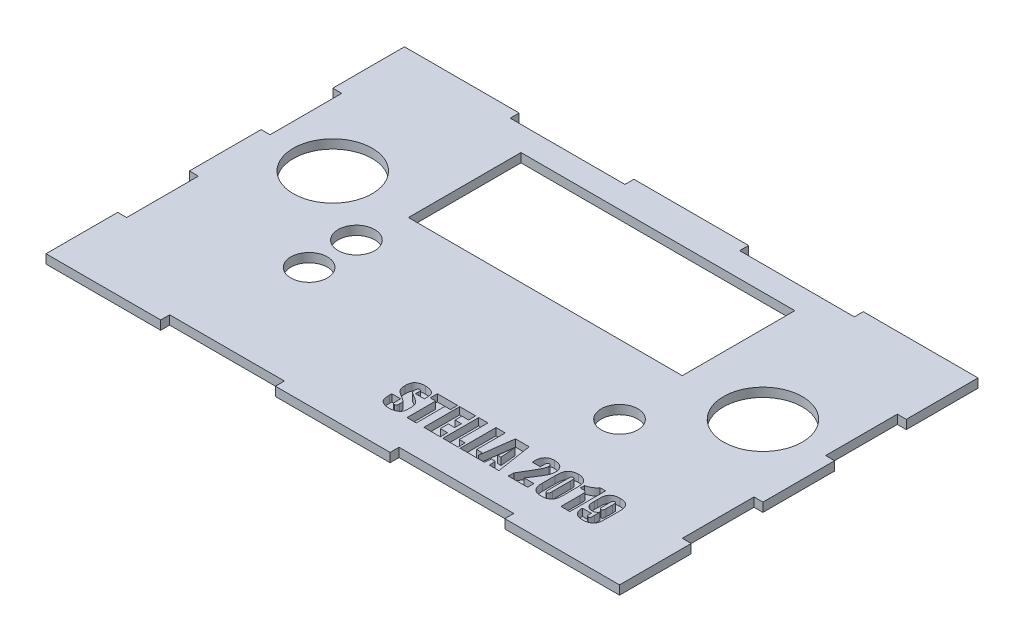
from build123d import *

# Parameters (mm, degrees)
SKETCH1_W           = 203.2
SKETCH1_H           = 127
BOSS_EXTRUDE2_DEPTH = 3.175
SKETCH2_W           = 40.64
SKETCH2_H           = 3.175
CUT_EXTRUDE1_DEPTH  = 3.175
LPATTERN2_COUNT     = 2
LPATTERN2_PITCH     = 81.28
SKETCH3_W           = 3.175
SKETCH3_H           = 25.4
CUT_EXTRUDE2_DEPTH  = 3.175
LPATTERN3_COUNT     = 2
LPATTERN3_PITCH     = 50.8
SKETCH6_W           = 3.175
SKETCH6_H           = 25.4
CUT_EXTRUDE3_DEPTH  = 3.175
LPATTERN4_COUNT     = 2
LPATTERN4_PITCH     = 50.8
SKETCH7_W           = 40.64
SKETCH7_H           = 3.175
CUT_EXTRUDE5_DEPTH  = 3.175
LPATTERN6_COUNT     = 2
LPATTERN6_PITCH     = 81.28
SKETCH9_W           = 97.028
SKETCH9_H           = 39.878
CUT_EXTRUDE6_DEPTH  = 3.175
SKETCH10_R          = 13.97
CUT_EXTRUDE7_DEPTH  = 3.175
SKETCH11_R          = 13.97
SKETCH11_R_2        = 6.477
CUT_EXTRUDE15_DEPTH = 3.175
CUT_EXTRUDE16_DEPTH = 2.54


with BuildPart() as part:
    # Sketch1 → Boss-Extrude2 (new body)
    with BuildSketch(Plane(origin=(0, 0, 0), x_dir=(1, 0, 0), z_dir=(0, 1, 0))):
        Rectangle(SKETCH1_W, SKETCH1_H)
    extrude(amount=BOSS_EXTRUDE2_DEPTH)

    # Sketch2 → Cut-Extrude1 (cut)
    with BuildSketch(Plane(origin=(0, 3.175, 0), x_dir=(1, 0, 0), z_dir=(0, 1, 0))):
        with Locations((-40.64, -61.9125)):
            Rectangle(SKETCH2_W, SKETCH2_H)
    cut_extrude1 = extrude(amount=-CUT_EXTRUDE1_DEPTH, mode=Mode.SUBTRACT)

    # LPattern2: Cut-Extrude1 ×2
    with Locations(*[(i * LPATTERN2_PITCH, 0, 0) for i in range(1, LPATTERN2_COUNT)]):
        add(cut_extrude1, mode=Mode.SUBTRACT)

    # Sketch3 → Cut-Extrude2 (cut)
    with BuildSketch(Plane(origin=(0, 3.175, 0), x_dir=(1, 0, 0), z_dir=(0, 1, 0))):
        with Locations((-100.0125, -25.4)):
            Rectangle(SKETCH3_W, SKETCH3_H)
    cut_extrude2 = extrude(amount=-CUT_EXTRUDE2_DEPTH, mode=Mode.SUBTRACT)

    # LPattern3: Cut-Extrude2 ×2
    with Locations(*[(0, 0, -i * LPATTERN3_PITCH) for i in range(1, LPATTERN3_COUNT)]):
        add(cut_extrude2, mode=Mode.SUBTRACT)

    # Sketch6 → Cut-Extrude3 (cut)
    with BuildSketch(Plane(origin=(0, 3.175, 0), x_dir=(1, 0, 0), z_dir=(0, 1, 0))):
        with Locations((100.0125, -25.4)):
            Rectangle(SKETCH6_W, SKETCH6_H)
    cut_extrude3 = extrude(amount=-CUT_EXTRUDE3_DEPTH, mode=Mode.SUBTRACT)

    # LPattern4: Cut-Extrude3 ×2
    with Locations(*[(0, 0, -i * LPATTERN4_PITCH) for i in range(1, LPATTERN4_COUNT)]):
        add(cut_extrude3, mode=Mode.SUBTRACT)

    # Sketch7 → Cut-Extrude5 (cut)
    with BuildSketch(Plane(origin=(0, 3.175, 0), x_dir=(1, 0, 0), z_dir=(0, 1, 0))):
        with Locations((-40.64, 61.9125)):
            Rectangle(SKETCH7_W, SKETCH7_H)
    cut_extrude5 = extrude(amount=-CUT_EXTRUDE5_DEPTH, mode=Mode.SUBTRACT)

    # LPattern6: Cut-Extrude5 ×2
    with Locations(*[(i * LPATTERN6_PITCH, 0, 0) for i in range(1, LPATTERN6_COUNT)]):
        add(cut_extrude5, mode=Mode.SUBTRACT)

    # Sketch9 → Cut-Extrude6 (cut)
    with BuildSketch(Plane(origin=(0, 3.175, 0), x_dir=(1, 0, 0), z_dir=(0, 1, 0))):
        with Locations((0, 31.75)):
            Rectangle(SKETCH9_W, SKETCH9_H)
    extrude(amount=-CUT_EXTRUDE6_DEPTH, mode=Mode.SUBTRACT)

    # Sketch10 → Cut-Extrude7 (cut)
    with BuildSketch(Plane(origin=(0, 3.175, 0), x_dir=(1, 0, 0), z_dir=(0, 1, 0))):
        with Locations((-76.2, 12.7)):
            Circle(SKETCH10_R)
    extrude(amount=-CUT_EXTRUDE7_DEPTH, mode=Mode.SUBTRACT)

    # Sketch11 → Cut-Extrude15 (cut)
    with BuildSketch(Plane(origin=(0, 3.175, 0), x_dir=(1, 0, 0), z_dir=(0, 1, 0))):
        with Locations((76.2, 12.7)):
            Circle(SKETCH11_R)
        with Locations((-50.8, -4.318)):
            Circle(SKETCH11_R_2)
        with Locations((-50.8, -21.082)):
            Circle(SKETCH11_R_2)
        with Locations((50.8, -12.7)):
            Circle(SKETCH11_R_2)
    extrude(amount=-CUT_EXTRUDE15_DEPTH, mode=Mode.SUBTRACT)

    # Sketch12 → Cut-Extrude16 (cut)
    with BuildSketch(Plane(origin=(0, 3.175, 0), x_dir=(1, 0, 0), z_dir=(0, 1, 0))):
        with BuildLine():
            Line((9.930258202, -41.00708394), (6.792611143, -41.00708394))
            Line((6.792611143, -41.00708394), (6.792611143, -40.003223645))
            add(Edge.make_bspline(
                [(6.792611143, -40.003223645), (6.791812116, -39.896558981), (6.790374848, -39.704693759), (6.76848043, -39.448334636), (6.733262434, -39.254011954), (6.677701373, -39.113864424), (6.597300117, -39.01992962), (6.498249038, -38.959276857), (6.379142296, -38.919770101), (6.292593657, -38.916869766), (6.246324379, -38.915319234)],
                knots=[0, 0, 0, 0, 0.000319911, 0.000575447, 0.000770951, 0.000911044, 0.001021954, 0.001135295, 0.001255632, 0.001393865, 0.001393865, 0.001393865, 0.001393865], degree=3))
            add(Edge.make_bspline(
                [(6.246324379, -38.915319234), (6.196136753, -38.918351267), (6.099594777, -38.924183749), (5.963481861, -38.972332752), (5.848467833, -39.05500618), (5.752748404, -39.168462924), (5.679995413, -39.314803852), (5.634707481, -39.493741734), (5.59998927, -39.702299025), (5.598246811, -39.852851348), (5.597317026, -39.933186881)],
                knots=[0, 0, 0, 0, 0.000150303, 0.000289126, 0.000426449, 0.000570531, 0.000730273, 0.000912099, 0.00112243, 0.001363071, 0.001363071, 0.001363071, 0.001363071], degree=3))
            add(Edge.make_bspline(
                [(5.597317026, -39.933186881), (5.598489748, -40.036820334), (5.600682477, -40.230591629), (5.632302643, -40.500441071), (5.675630111, -40.73214216), (5.730716931, -40.866075093), (5.756067026, -40.92770894)],
                knots=[0, 0, 0, 0, 0.000310637, 0.000580821, 0.000814801, 0.001014266, 0.001014266, 0.001014266, 0.001014266], degree=3))
            add(Edge.make_bspline(
                [(5.756067026, -40.92770894), (5.771709844, -40.956173484), (5.805294139, -41.017285341), (5.875214301, -41.106022637), (5.96406191, -41.200173191), (6.076752729, -41.293222984), (6.206720453, -41.393348976), (6.358202789, -41.495088099), (6.531327924, -41.599287217), (6.653928921, -41.668828569), (6.717905261, -41.705117028)],
                knots=[0, 0, 0, 0, 9.7298e-05, 0.000208894, 0.000337697, 0.000485071, 0.000646628, 0.000829873, 0.001032065, 0.001252715, 0.001252715, 0.001252715, 0.001252715], degree=3))
            add(Edge.make_bspline(
                [(6.717905261, -41.705117028), (6.902854819, -41.808487249), (7.257197705, -42.006533153), (7.757655385, -42.305166833), (8.203623955, -42.590925405), (8.594647297, -42.865176377), (8.934590897, -43.121551001), (9.217696681, -43.368536753), (9.454480219, -43.595727727), (9.577108637, -43.757262704), (9.633769232, -43.831900116)],
                knots=[0, 0, 0, 0, 0.000635605, 0.001217748, 0.00174811, 0.002224142, 0.002650453, 0.003024464, 0.003351319, 0.003632059, 0.003632059, 0.003632059, 0.003632059], degree=3))
            add(Edge.make_bspline(
                [(9.633769232, -43.831900116), (9.682316521, -43.90711219), (9.78303355, -44.063148434), (9.902342903, -44.326786714), (10.002340127, -44.622016067), (10.085530663, -44.948304687), (10.150591979, -45.307933791), (10.195879875, -45.699371677), (10.224263415, -46.123239014), (10.227437281, -46.4162089), (10.229081732, -46.568003057)],
                knots=[0, 0, 0, 0, 0.000268261, 0.000556539, 0.000865142, 0.001202613, 0.001565733, 0.001960708, 0.002384191, 0.002839526, 0.002839526, 0.002839526, 0.002839526], degree=3))
            add(Edge.make_bspline(
                [(10.229081732, -46.568003057), (10.228460745, -46.678529142), (10.227257382, -46.892709138), (10.210247897, -47.202613351), (10.18497434, -47.489977746), (10.151304335, -47.754446323), (10.10405423, -47.995872283), (10.04893836, -48.215222712), (9.984053207, -48.413265823), (9.906545645, -48.591122587), (9.813269663, -48.753873257), (9.701953852, -48.906359376), (9.573566845, -49.053751915), (9.425454528, -49.193896726), (9.258724221, -49.327927409), (9.071800281, -49.452567732), (8.866729648, -49.572484862), (8.5672061, -49.725948343), (8.158411383, -49.884986144), (7.632443943, -50.023841232), (7.06830021, -50.10536844), (6.679262403, -50.115834853), (6.479780261, -50.121201587)],
                knots=[0, 0, 0, 0, 0.00033154, 0.000642466, 0.000930763, 0.001196882, 0.001441833, 0.001668321, 0.001875032, 0.002066323, 0.00224933, 0.00243659, 0.002631829, 0.002834936, 0.003047496, 0.003272826, 0.003508258, 0.003759882, 0.004281843, 0.004820362, 0.005388893, 0.005987196, 0.005987196, 0.005987196, 0.005987196], degree=3))
            add(Edge.make_bspline(
                [(6.479780261, -50.121201587), (6.368434133, -50.120375011), (6.150093984, -50.118754167), (5.829260674, -50.09071429), (5.521129398, -50.052815232), (5.225021607, -49.995866366), (4.940786711, -49.924765027), (4.669365705, -49.834557911), (4.40882034, -49.733773576), (4.165204222, -49.611330395), (3.936649657, -49.478937699), (3.726939039, -49.337733141), (3.538218714, -49.186791726), (3.369388711, -49.028389792), (3.22106123, -48.859825291), (3.095556825, -48.681107752), (2.985589074, -48.496899088), (2.901492723, -48.298030088), (2.832167132, -48.08586399), (2.770069021, -47.855526761), (2.723800316, -47.603722659), (2.680432958, -47.331499515), (2.648875285, -47.038503001), (2.625650258, -46.724728475), (2.611570612, -46.390705437), (2.609927847, -46.161025431), (2.609081732, -46.042727322)],
                knots=[0, 0, 0, 0, 0.000333915, 0.000654779, 0.000965486, 0.001264929, 0.001558796, 0.001843765, 0.002122518, 0.00239606, 0.002660732, 0.002914555, 0.003153731, 0.003384935, 0.003608285, 0.003825938, 0.004039355, 0.004250565, 0.004472041, 0.004708743, 0.004965597, 0.005239647, 0.005535611, 0.005849312, 0.006183448, 0.006538332, 0.006538332, 0.006538332, 0.006538332], degree=3))
            Line((2.609081732, -46.042727322), (2.609081732, -45.190613351))
            Line((2.609081732, -45.190613351), (5.74672879, -45.190613351))
            Line((5.74672879, -45.190613351), (5.74672879, -46.836477322))
            add(Edge.make_bspline(
                [(5.74672879, -46.836477322), (5.747014256, -46.897192584), (5.747556122, -47.012441437), (5.755925607, -47.17656627), (5.762753416, -47.32410626), (5.781086104, -47.45452808), (5.796811272, -47.569236818), (5.824026261, -47.665341613), (5.850571078, -47.745967972), (5.893511749, -47.830272973), (5.967185741, -47.913383126), (6.082459454, -47.983616305), (6.225268657, -48.022322806), (6.328574136, -48.026950939), (6.384063349, -48.029436881)],
                knots=[0, 0, 0, 0, 0.000182111, 0.00034568, 0.000493053, 0.000624806, 0.000740714, 0.000839816, 0.000923989, 0.000994992, 0.00112237, 0.0012513, 0.001394643, 0.001560988, 0.001560988, 0.001560988, 0.001560988], degree=3))
            add(Edge.make_bspline(
                [(6.384063349, -48.029436881), (6.440608276, -48.026974272), (6.548576734, -48.022272099), (6.697343703, -47.967975646), (6.825075766, -47.88451677), (6.923952004, -47.761774748), (7.002162807, -47.608659715), (7.052371096, -47.422673369), (7.085711992, -47.206532891), (7.089439057, -47.052188952), (7.091434673, -46.969547175)],
                knots=[0, 0, 0, 0, 0.000168881, 0.000322466, 0.0004688, 0.000621245, 0.000789349, 0.000981437, 0.001196381, 0.00144412, 0.00144412, 0.00144412, 0.00144412], degree=3))
            add(Edge.make_bspline(
                [(7.091434673, -46.969547175), (7.090641082, -46.877697109), (7.089120138, -46.70166334), (7.074914372, -46.450116264), (7.053286803, -46.22218506), (7.017528317, -46.020664823), (6.977611145, -45.842341704), (6.923068758, -45.691502868), (6.864768269, -45.560889893), (6.81103241, -45.490199828), (6.785607467, -45.456753057)],
                knots=[0, 0, 0, 0, 0.000275518, 0.000528039, 0.000755691, 0.000961794, 0.001141858, 0.001302824, 0.001442742, 0.001568397, 0.001568397, 0.001568397, 0.001568397], degree=3))
            add(Edge.make_bspline(
                [(6.785607467, -45.456753057), (6.754988982, -45.424321714), (6.686103225, -45.351357369), (6.559067272, -45.243610082), (6.400983405, -45.122697766), (6.215415254, -44.984696089), (5.996655154, -44.835567573), (5.747802421, -44.672556076), (5.46582187, -44.497506911), (5.267452007, -44.376487745), (5.163089085, -44.312819234)],
                knots=[0, 0, 0, 0, 0.000133724, 0.000300853, 0.00049885, 0.000730913, 0.00099447, 0.001292974, 0.001623337, 0.001990093, 0.001990093, 0.001990093, 0.001990093], degree=3))
            add(Edge.make_bspline(
                [(5.163089085, -44.312819234), (5.058682428, -44.249218905), (4.857834224, -44.12687027), (4.572038773, -43.948161624), (4.313628539, -43.781645021), (4.08444486, -43.628509712), (3.881396979, -43.49018674), (3.707196836, -43.364640223), (3.558964609, -43.253119596), (3.398250217, -43.118837999), (3.224560465, -42.939868848), (3.039495169, -42.697927099), (2.874190832, -42.420070202), (2.72545922, -42.107202968), (2.602085284, -41.752887528), (2.522635533, -41.351487138), (2.466293031, -40.907512197), (2.461941863, -40.595628037), (2.459669967, -40.432782469)],
                knots=[0, 0, 0, 0, 0.000366756, 0.000705533, 0.001011182, 0.001288955, 0.001532433, 0.001748187, 0.001933089, 0.002088824, 0.002376079, 0.002679122, 0.003000622, 0.003344191, 0.003717027, 0.004122703, 0.004569508, 0.005057704, 0.005057704, 0.005057704, 0.005057704], degree=3))
            add(Edge.make_bspline(
                [(2.459669967, -40.432782469), (2.461388237, -40.313710089), (2.464702872, -40.084013158), (2.47944386, -39.752043768), (2.510340609, -39.445196786), (2.551251314, -39.162911515), (2.605115813, -38.904891477), (2.668586313, -38.670633422), (2.748566023, -38.462685818), (2.838188287, -38.276171048), (2.942826978, -38.107515416), (3.062857305, -37.952219547), (3.193707431, -37.802083672), (3.343895811, -37.666487567), (3.506399567, -37.536433563), (3.682938857, -37.415213209), (3.875726129, -37.30588588), (4.15435752, -37.169441679), (4.536256166, -37.029181668), (5.033274538, -36.907830116), (5.574172539, -36.835388615), (5.949607806, -36.827586209), (6.14360379, -36.823554528)],
                knots=[0, 0, 0, 0, 0.000357256, 0.000689166, 0.000996495, 0.001282086, 0.001544441, 0.001786875, 0.002009296, 0.002211852, 0.002406854, 0.002603429, 0.002800212, 0.003003426, 0.003209423, 0.003424405, 0.003645055, 0.003873711, 0.004354613, 0.004861943, 0.005406061, 0.005987835, 0.005987835, 0.005987835, 0.005987835], degree=3))
            add(Edge.make_bspline(
                [(6.14360379, -36.823554528), (6.251781958, -36.825177227), (6.464408357, -36.828366677), (6.777135137, -36.845201488), (7.076451787, -36.882979815), (7.364836287, -36.924260515), (7.64006868, -36.986915685), (7.904166278, -37.057708231), (8.155220591, -37.144620494), (8.392436846, -37.245060834), (8.614164576, -37.354000943), (8.819843294, -37.46686081), (9.001188517, -37.59334443), (9.169518321, -37.71843422), (9.310835443, -37.859519463), (9.439932194, -38.000591012), (9.544173337, -38.152990316), (9.631877199, -38.314700072), (9.701488905, -38.494995259), (9.765105304, -38.697333508), (9.814490828, -38.929030738), (9.859808616, -39.187294871), (9.890751761, -39.475121017), (9.913902355, -39.790458766), (9.927823185, -40.133835428), (9.929425782, -40.372071182), (9.930258202, -40.495815557)],
                knots=[0, 0, 0, 0, 0.000324579, 0.000637967, 0.000938836, 0.001229392, 0.001511478, 0.00178503, 0.002049341, 0.002307761, 0.002557297, 0.002790402, 0.003010557, 0.003220226, 0.003418347, 0.003608539, 0.003793102, 0.003970667, 0.004159246, 0.004371909, 0.00460639, 0.004869295, 0.0051583, 0.005474329, 0.005817794, 0.006189019, 0.006189019, 0.006189019, 0.006189019], degree=3))
            Line((9.930258202, -40.495815557), (9.930258202, -41.00708394))
        make_face()
        Polygon((17.849081732, -37.122378057), (17.849081732, -39.662378057), (15.90672879, -39.662378057), (15.90672879, -49.822378057), (12.619669967, -49.822378057), (12.619669967, -39.662378057), (10.677317026, -39.662378057), (10.677317026, -37.122378057), align=None)
        Polygon((18.596140555, -37.122378057), (24.273787614, -37.122378057), (24.273787614, -39.662378057), (21.883199379, -39.662378057), (21.883199379, -42.052966293), (24.124375849, -42.052966293), (24.124375849, -44.443554528), (21.883199379, -44.443554528), (21.883199379, -47.282378057), (24.423199379, -47.282378057), (24.423199379, -49.822378057), (18.596140555, -49.822378057), align=None)
        Polygon((28.60672879, -37.122378057), (28.60672879, -47.282378057), (30.698493496, -47.282378057), (30.698493496, -49.822378057), (25.319669967, -49.822378057), (25.319669967, -37.122378057), align=None)
        Polygon((34.732611143, -37.122378057), (34.732611143, -47.282378057), (36.824375849, -47.282378057), (36.824375849, -49.822378057), (31.44555232, -49.822378057), (31.44555232, -37.122378057), align=None)
        Polygon((43.21172879, -37.122378057), (45.191434673, -49.822378057), (41.792317026, -49.822378057), (41.600883202, -47.581201587), (40.267850114, -47.581201587), (40.074081732, -49.822378057), (36.674964085, -49.822378057), (38.355846437, -37.122378057), align=None)
        with BuildLine():
            add(Edge.make_bspline(
                [(41.44680232, -45.340025116), (41.428789132, -45.148601983), (41.391739699, -44.754883858), (41.336872252, -44.147717685), (41.273892266, -43.507626668), (41.216372579, -42.833206147), (41.145406865, -42.12557754), (41.080179626, -41.383591005), (41.006473047, -40.608713296), (40.957957208, -40.08105565), (40.933199379, -39.811789822)],
                knots=[0, 0, 0, 0, 0.000576806, 0.001186372, 0.001828914, 0.002506327, 0.003216931, 0.003962401, 0.004740846, 0.005552051, 0.005552051, 0.005552051, 0.005552051], degree=3))
            add(Edge.make_bspline(
                [(40.933199379, -39.811789822), (40.89770827, -40.113762781), (40.829092604, -40.697573119), (40.724781114, -41.542305235), (40.632424803, -42.326155628), (40.546023422, -43.04830956), (40.465624833, -43.707997252), (40.397351738, -44.306818175), (40.330268713, -44.843375637), (40.290981368, -45.18124948), (40.272519232, -45.340025116)],
                knots=[0, 0, 0, 0, 0.000912152, 0.001763483, 0.002553433, 0.003279965, 0.003945396, 0.004547133, 0.005088046, 0.00556758, 0.00556758, 0.00556758, 0.00556758], degree=3))
            Line((40.272519232, -45.340025116), (41.44680232, -45.340025116))
        make_face(mode=Mode.SUBTRACT)
        with BuildLine():
            Line((55.351434673, -47.581201587), (55.351434673, -49.822378057))
            Line((55.351434673, -49.822378057), (48.478493496, -49.822378057))
            Line((48.478493496, -49.822378057), (48.515846437, -47.880025116))
            add(Edge.make_bspline(
                [(48.515846437, -47.880025116), (48.639716134, -47.675445523), (48.881095488, -47.276790394), (49.231877588, -46.692259092), (49.561782283, -46.137234046), (49.876587095, -45.61437303), (50.167261081, -45.119079766), (50.440643792, -44.654644924), (50.695186511, -44.220458747), (50.930640539, -43.816387001), (51.14918312, -43.443343168), (51.34349137, -43.097907242), (51.52233798, -42.784326417), (51.681008908, -42.500651236), (51.818395573, -42.245558477), (51.938559895, -42.021224988), (52.03782725, -41.826083805), (52.146172913, -41.61095618), (52.25941177, -41.368908722), (52.375846546, -41.094631999), (52.474400859, -40.8360173), (52.557688066, -40.595417093), (52.616799911, -40.369152319), (52.666802039, -40.161411125), (52.692336199, -39.968068929), (52.697115754, -39.844528082), (52.699375849, -39.786109675)],
                knots=[0, 0, 0, 0, 0.000717473, 0.001398108, 0.002045114, 0.002654483, 0.003229036, 0.00376796, 0.004271257, 0.004738926, 0.005170971, 0.005568258, 0.005927901, 0.006253972, 0.006543325, 0.006797106, 0.007017409, 0.007200118, 0.007519705, 0.007818893, 0.008093777, 0.008349951, 0.008582143, 0.008795101, 0.008990563, 0.009165904, 0.009165904, 0.009165904, 0.009165904], degree=3))
            add(Edge.make_bspline(
                [(52.699375849, -39.786109675), (52.696959797, -39.705873496), (52.692436415, -39.555653735), (52.664264001, -39.345623249), (52.611407306, -39.167730709), (52.536218349, -39.021138544), (52.439146528, -38.903950311), (52.315042, -38.821854065), (52.168020852, -38.774710615), (52.063169887, -38.768929987), (52.008346437, -38.765907469)],
                knots=[0, 0, 0, 0, 0.000240743, 0.000450723, 0.000633863, 0.000794677, 0.00094205, 0.001085146, 0.001235013, 0.001399247, 0.001399247, 0.001399247, 0.001399247], degree=3))
            add(Edge.make_bspline(
                [(52.008346437, -38.765907469), (51.953430523, -38.768543701), (51.847894567, -38.773609941), (51.700367149, -38.826698486), (51.576685639, -38.91655759), (51.496255005, -39.020208121), (51.444751101, -39.121704463), (51.409093968, -39.216150976), (51.383932109, -39.328142357), (51.356282639, -39.455226975), (51.338526894, -39.600513531), (51.328790014, -39.762692534), (51.317527069, -39.941605892), (51.317389306, -40.066234925), (51.317317026, -40.131624381)],
                knots=[0, 0, 0, 0, 0.000164234, 0.000315621, 0.000462717, 0.00061731, 0.000703972, 0.000803704, 0.000919212, 0.001047867, 0.001193809, 0.001357645, 0.001535317, 0.001731434, 0.001731434, 0.001731434, 0.001731434], degree=3))
            Line((51.317317026, -40.131624381), (51.317317026, -41.305907469))
            Line((51.317317026, -41.305907469), (48.478493496, -41.305907469))
            Line((48.478493496, -41.305907469), (48.478493496, -40.850668498))
            add(Edge.make_bspline(
                [(48.478493496, -40.850668498), (48.479625122, -40.685666013), (48.481766646, -40.373410311), (48.503050052, -39.932694056), (48.53438954, -39.546998206), (48.578728397, -39.206424486), (48.654902669, -38.893770997), (48.771816348, -38.593920094), (48.924313772, -38.2948459), (49.116909954, -38.004504839), (49.341740171, -37.729003128), (49.606873734, -37.488821395), (49.903368472, -37.285123247), (50.231222367, -37.114517353), (50.593834978, -36.985513428), (50.987822486, -36.88921163), (51.416112904, -36.833470985), (51.712471315, -36.826937727), (51.865938349, -36.823554528)],
                knots=[0, 0, 0, 0, 0.000494976, 0.000936708, 0.001323294, 0.001655762, 0.001966047, 0.002286018, 0.002619084, 0.002971324, 0.003329418, 0.003683071, 0.004040533, 0.004405986, 0.004788541, 0.005192257, 0.005620825, 0.006081113, 0.006081113, 0.006081113, 0.006081113], degree=3))
            add(Edge.make_bspline(
                [(51.865938349, -36.823554528), (52.017034003, -36.825830653), (52.310581404, -36.83025269), (52.73654567, -36.876215243), (53.134583921, -36.946330948), (53.504392209, -37.04968905), (53.845650329, -37.182097238), (54.158508968, -37.343363416), (54.442139407, -37.534561644), (54.696319745, -37.753751753), (54.919266723, -37.997022912), (55.115117011, -38.255598139), (55.281120702, -38.529284598), (55.418564825, -38.818061311), (55.520532016, -39.124365457), (55.594470942, -39.444848991), (55.643944367, -39.780691528), (55.648126477, -40.010047064), (55.650258202, -40.126955263)],
                knots=[0, 0, 0, 0, 0.000453121, 0.00088032, 0.001283739, 0.001664387, 0.002030288, 0.002380082, 0.002718078, 0.0030541, 0.00338452, 0.003706224, 0.004025726, 0.0043432, 0.004663605, 0.004992049, 0.00532914, 0.005679604, 0.005679604, 0.005679604, 0.005679604], degree=3))
            add(Edge.make_bspline(
                [(55.650258202, -40.126955263), (55.648262649, -40.218060806), (55.644229968, -40.402169956), (55.61734748, -40.680407236), (55.575517772, -40.962530442), (55.516739147, -41.249445853), (55.440011439, -41.539279658), (55.344912302, -41.833219609), (55.236377999, -42.131566042), (55.127938795, -42.38495471), (55.026527382, -42.599409947), (54.934743012, -42.783552251), (54.824796509, -42.9877505), (54.698692535, -43.21421115), (54.556054848, -43.461571513), (54.397297275, -43.730063875), (54.221285402, -44.019779769), (54.031338652, -44.331983288), (53.821736371, -44.663917485), (53.598875107, -45.019292709), (53.355731201, -45.393167157), (53.09849908, -45.790000853), (52.82286432, -46.205987113), (52.533321213, -46.646652378), (52.226076366, -47.107444593), (52.013974948, -47.421017283), (51.905625849, -47.581201587)],
                knots=[0, 0, 0, 0, 0.000273303, 0.0005523, 0.00083789, 0.001128625, 0.001430442, 0.001736839, 0.002055171, 0.002382559, 0.002563227, 0.002766816, 0.002999723, 0.003258901, 0.003544415, 0.003856312, 0.00419463, 0.004561386, 0.004952625, 0.005372326, 0.005819789, 0.006290543, 0.006791059, 0.007316828, 0.007872374, 0.008452534, 0.008452534, 0.008452534, 0.008452534], degree=3))
            Line((51.905625849, -47.581201587), (55.351434673, -47.581201587))
        make_face()
        with BuildLine():
            Line((64.16672879, -41.40395894), (64.16672879, -45.676201587))
            add(Edge.make_bspline(
                [(64.16672879, -45.676201587), (64.166345825, -45.792935543), (64.165605352, -46.018643781), (64.158111836, -46.345496282), (64.148273316, -46.647647622), (64.127368214, -46.925260438), (64.109376782, -47.177907944), (64.079249573, -47.405603113), (64.051046005, -47.609426591), (64.001566636, -47.848158505), (63.915903161, -48.126114044), (63.774708872, -48.445122508), (63.58830778, -48.751575318), (63.363466331, -49.042566421), (63.108008381, -49.310822341), (62.819149905, -49.538626525), (62.507589923, -49.730273792), (62.167942012, -49.877018954), (61.806666609, -49.984669149), (61.425803081, -50.065221233), (61.024000362, -50.111513264), (60.749050863, -50.117929905), (60.608861143, -50.121201587)],
                knots=[0, 0, 0, 0, 0.000350192, 0.000677105, 0.000980822, 0.001256932, 0.001512265, 0.001740444, 0.001945805, 0.002129406, 0.002471313, 0.002816204, 0.003173338, 0.003544563, 0.003917698, 0.004281567, 0.004645114, 0.005012056, 0.005387949, 0.005774387, 0.006178637, 0.006599175, 0.006599175, 0.006599175, 0.006599175], degree=3))
            add(Edge.make_bspline(
                [(60.608861143, -50.121201587), (60.427444232, -50.11823837), (60.079453752, -50.112554384), (59.581011267, -50.064987925), (59.130626327, -49.980592229), (58.724372703, -49.868954935), (58.362124087, -49.71634527), (58.041452222, -49.524509456), (57.75472226, -49.300718688), (57.513641276, -49.036104229), (57.307919459, -48.752923197), (57.134302661, -48.457883409), (56.988231555, -48.158388432), (56.894858, -47.897132339), (56.834303202, -47.674533162), (56.799248174, -47.483737606), (56.765456308, -47.270636916), (56.741552912, -47.035172671), (56.719394485, -46.776870706), (56.707087811, -46.495716829), (56.696599353, -46.191439497), (56.696297196, -45.981261976), (56.696140555, -45.872304528)],
                knots=[0, 0, 0, 0, 0.000544198, 0.00104387, 0.001499916, 0.001917437, 0.002305521, 0.002675068, 0.003035657, 0.003392471, 0.00374502, 0.004084143, 0.004418278, 0.004743193, 0.004914779, 0.005109823, 0.005324767, 0.005561952, 0.005819612, 0.00610244, 0.006406077, 0.006732923, 0.006732923, 0.006732923, 0.006732923], degree=3))
            Line((56.696140555, -45.872304528), (56.696140555, -41.40395894))
            add(Edge.make_bspline(
                [(56.696140555, -41.40395894), (56.696964686, -41.261537601), (56.698559335, -40.985960082), (56.712823813, -40.585841868), (56.735294819, -40.213638231), (56.768309017, -39.868763357), (56.808141882, -39.552056683), (56.86349667, -39.263600354), (56.922372954, -39.001936923), (56.993019048, -38.764446276), (57.076915962, -38.54516674), (57.183606224, -38.342499534), (57.305221479, -38.148283098), (57.4483202, -37.967428667), (57.607456905, -37.795414239), (57.786700886, -37.636572034), (57.982831797, -37.486756998), (58.197544476, -37.349320248), (58.427446967, -37.226962451), (58.669634368, -37.11816799), (58.924346472, -37.027770488), (59.191110986, -36.952937115), (59.469597932, -36.894958818), (59.760278587, -36.852177587), (60.063010257, -36.830098324), (60.268763928, -36.825755912), (60.373070702, -36.823554528)],
                knots=[0, 0, 0, 0, 0.00042725, 0.000826705, 0.001200963, 0.001545696, 0.001865965, 0.002158093, 0.002426516, 0.002670252, 0.002900889, 0.003129557, 0.003356237, 0.003587406, 0.003820312, 0.004058392, 0.004304928, 0.004560079, 0.004822237, 0.005085587, 0.005355852, 0.005632278, 0.005916155, 0.006208674, 0.006513064, 0.006826034, 0.006826034, 0.006826034, 0.006826034], degree=3))
            add(Edge.make_bspline(
                [(60.373070702, -36.823554528), (60.54214756, -36.828120025), (60.873141383, -36.837057685), (61.356506398, -36.904605939), (61.811833486, -37.02187044), (62.234464384, -37.182240645), (62.616316374, -37.37487729), (62.954835337, -37.586246428), (63.239720092, -37.82217616), (63.472697322, -38.081112171), (63.659342584, -38.358949057), (63.818691782, -38.64907533), (63.939622941, -38.959502976), (64.013041826, -39.233030163), (64.060631666, -39.469179945), (64.086440346, -39.673023232), (64.112665388, -39.900918762), (64.134055844, -40.15389471), (64.146125002, -40.431178742), (64.158785883, -40.733067791), (64.165437997, -41.059971262), (64.166287847, -41.286450515), (64.16672879, -41.40395894)],
                knots=[0, 0, 0, 0, 0.000507137, 0.000992798, 0.001460503, 0.001914903, 0.002346096, 0.002741802, 0.003109759, 0.003451953, 0.003782844, 0.004111884, 0.004443095, 0.004779507, 0.004960356, 0.005165386, 0.005395609, 0.005648615, 0.005926781, 0.006228165, 0.006555078, 0.006907604, 0.006907604, 0.006907604, 0.006907604], degree=3))
        make_face()
        with BuildLine():
            add(Edge.make_bspline(
                [(61.029081732, -40.309050851), (61.028532767, -40.227337083), (61.027492259, -40.072456797), (61.022498518, -39.852231321), (61.016805749, -39.655979101), (61.004268397, -39.483275811), (60.991950294, -39.334270335), (60.972934321, -39.209729936), (60.952578694, -39.108937998), (60.923927757, -39.007581897), (60.866267045, -38.904223352), (60.752117197, -38.823036336), (60.608221796, -38.772651181), (60.501194478, -38.768279898), (60.443107467, -38.765907469)],
                knots=[0, 0, 0, 0, 0.00024514, 0.000464638, 0.000660866, 0.000834017, 0.000984084, 0.001109217, 0.001211779, 0.001292279, 0.001425205, 0.001556875, 0.001703079, 0.001876607, 0.001876607, 0.001876607, 0.001876607], degree=3))
            add(Edge.make_bspline(
                [(60.443107467, -38.765907469), (60.385812412, -38.768206812), (60.279321523, -38.772480462), (60.133948433, -38.825359197), (60.019822408, -38.915387688), (59.957299354, -39.02229003), (59.920954126, -39.12699838), (59.899656489, -39.230011692), (59.877750144, -39.354385303), (59.863073355, -39.501917434), (59.848469942, -39.671494759), (59.839608838, -39.863845078), (59.835616412, -40.078689364), (59.834417771, -40.229674171), (59.833787614, -40.309050851)],
                knots=[0, 0, 0, 0, 0.000171205, 0.000318208, 0.000456026, 0.000598568, 0.000682741, 0.000788081, 0.000913584, 0.001061567, 0.001232564, 0.001424226, 0.001639056, 0.001877192, 0.001877192, 0.001877192, 0.001877192], degree=3))
            Line((59.833787614, -40.309050851), (59.833787614, -46.596017763))
            add(Edge.make_bspline(
                [(59.833787614, -46.596017763), (59.834443389, -46.684730421), (59.835686001, -46.852829765), (59.839315274, -47.091040671), (59.849213543, -47.301922162), (59.860347242, -47.484881429), (59.87379603, -47.640711453), (59.890780911, -47.76819844), (59.914551065, -47.867892318), (59.945360609, -47.963947368), (60.011855562, -48.054583044), (60.122690891, -48.128367628), (60.264717332, -48.173761234), (60.369570497, -48.177053039), (60.426765555, -48.178848645)],
                knots=[0, 0, 0, 0, 0.00026615, 0.000504321, 0.000714638, 0.000899438, 0.001054154, 0.001183906, 0.001284698, 0.001361491, 0.001485244, 0.001612815, 0.001755299, 0.001926297, 0.001926297, 0.001926297, 0.001926297], degree=3))
            add(Edge.make_bspline(
                [(60.426765555, -48.178848645), (60.484071683, -48.176556976), (60.590583155, -48.172297588), (60.734776044, -48.119706546), (60.84787627, -48.031821409), (60.908310142, -47.92606491), (60.943385066, -47.82380638), (60.966878529, -47.723685041), (60.982823393, -47.603058907), (61.004332383, -47.461941285), (61.012981085, -47.298749188), (61.023628225, -47.115196361), (61.027148017, -46.910412146), (61.028414265, -46.767216272), (61.029081732, -46.691734675)],
                knots=[0, 0, 0, 0, 0.000171205, 0.000318208, 0.000452744, 0.000592076, 0.00067625, 0.000777042, 0.000899868, 0.001041181, 0.001205016, 0.001389683, 0.001592843, 0.001819307, 0.001819307, 0.001819307, 0.001819307], degree=3))
            Line((61.029081732, -46.691734675), (61.029081732, -40.309050851))
        make_face(mode=Mode.SUBTRACT)
        with BuildLine():
            Line((70.292611143, -37.122378057), (70.292611143, -49.822378057))
            Line((70.292611143, -49.822378057), (67.154964085, -49.822378057))
            Line((67.154964085, -49.822378057), (67.154964085, -43.066164822))
            add(Edge.make_bspline(
                [(67.154964085, -43.066164822), (67.155495987, -42.950210211), (67.15650273, -42.73074079), (67.14982213, -42.419502378), (67.147548902, -42.144699796), (67.136769524, -41.906633327), (67.128017884, -41.705042324), (67.118289297, -41.539687137), (67.101157691, -41.411424266), (67.081861302, -41.289122505), (67.037246928, -41.165636231), (66.950199542, -41.040399313), (66.8295667, -40.937177111), (66.706008435, -40.866309449), (66.58328775, -40.82045975), (66.463796854, -40.792445495), (66.320939439, -40.762985309), (66.152176856, -40.743943088), (65.958348482, -40.727531445), (65.739546373, -40.716456002), (65.495918724, -40.709404847), (65.325454065, -40.708654406), (65.235956732, -40.70826041)],
                knots=[0, 0, 0, 0, 0.000347849, 0.000658381, 0.000933898, 0.001172206, 0.001373195, 0.00153936, 0.001668796, 0.001761299, 0.001910492, 0.002058142, 0.002213631, 0.002383028, 0.00248276, 0.00260563, 0.002750767, 0.002920164, 0.00311462, 0.003334379, 0.003577274, 0.003845758, 0.003845758, 0.003845758, 0.003845758], degree=3))
            Line((65.235956732, -40.70826041), (64.913787614, -40.70826041))
            Line((64.913787614, -40.70826041), (64.913787614, -39.251495704))
            add(Edge.make_bspline(
                [(64.913787614, -39.251495704), (65.097481404, -39.205313689), (65.457158506, -39.114888132), (65.973276646, -38.933440886), (66.456304221, -38.718819622), (66.905216633, -38.469399403), (67.319723364, -38.185022453), (67.69918917, -37.865694615), (68.047712469, -37.513858146), (68.249331259, -37.252972822), (68.350258202, -37.122378057)],
                knots=[0, 0, 0, 0, 0.000567994, 0.001112146, 0.001638847, 0.002151988, 0.002650606, 0.003144408, 0.003638017, 0.004132778, 0.004132778, 0.004132778, 0.004132778], degree=3))
            Line((68.350258202, -37.122378057), (70.292611143, -37.122378057))
        make_face()
        with BuildLine():
            Line((71.487905261, -46.535319234), (74.62555232, -46.535319234))
            add(Edge.make_bspline(
                [(74.62555232, -46.535319234), (74.62523232, -46.604579553), (74.624621062, -46.736879348), (74.62873727, -46.92518284), (74.627350189, -47.094059028), (74.629075164, -47.242746398), (74.635674408, -47.371041072), (74.635922249, -47.478562498), (74.641785112, -47.565640481), (74.646051627, -47.654270368), (74.66423013, -47.748675932), (74.702410163, -47.851033682), (74.755739155, -47.945060109), (74.826796745, -48.027600496), (74.912843744, -48.096790558), (75.01757238, -48.143017232), (75.13417845, -48.174728832), (75.21752178, -48.177445841), (75.26055232, -48.178848645)],
                knots=[0, 0, 0, 0, 0.000207776, 0.000396889, 0.000564978, 0.000714408, 0.000842893, 0.000950308, 0.001036813, 0.001104676, 0.001216394, 0.001323504, 0.001431223, 0.001538841, 0.00164859, 0.001759303, 0.001879912, 0.002008652, 0.002008652, 0.002008652, 0.002008652], degree=3))
            add(Edge.make_bspline(
                [(75.26055232, -48.178848645), (75.297299785, -48.17718615), (75.368076438, -48.173984138), (75.469835966, -48.145399546), (75.559002325, -48.094446495), (75.639532423, -48.029418831), (75.704902798, -47.94695788), (75.753791291, -47.85142956), (75.79029323, -47.746281799), (75.804445055, -47.620419626), (75.813598379, -47.461542861), (75.816049673, -47.249667575), (75.822518195, -46.977366928), (75.821439617, -46.775009331), (75.820846437, -46.663719969)],
                knots=[0, 0, 0, 0, 0.000110121, 0.000212096, 0.000313455, 0.000416281, 0.000520921, 0.00062639, 0.000737128, 0.000852682, 0.001004716, 0.001214878, 0.001488061, 0.001821903, 0.001821903, 0.001821903, 0.001821903], degree=3))
            Line((75.820846437, -46.663719969), (75.820846437, -44.592966293))
            add(Edge.make_bspline(
                [(75.820846437, -44.592966293), (75.780766583, -44.676261248), (75.702274722, -44.839384993), (75.539965619, -45.053568981), (75.351391042, -45.236277604), (75.133282991, -45.38486539), (74.886620933, -45.500469816), (74.611756151, -45.580498305), (74.309868631, -45.630536127), (74.099707126, -45.636007101), (73.99055232, -45.638848645)],
                knots=[0, 0, 0, 0, 0.000276722, 0.000541928, 0.000801148, 0.001061459, 0.001329852, 0.001614955, 0.001917774, 0.00224502, 0.00224502, 0.00224502, 0.00224502], degree=3))
            add(Edge.make_bspline(
                [(73.99055232, -45.638848645), (73.852306015, -45.633148563), (73.581408555, -45.621979094), (73.188836785, -45.530087851), (72.820969948, -45.381755505), (72.486585269, -45.175061149), (72.195540249, -44.927762223), (71.953524198, -44.654464115), (71.772678327, -44.35382251), (71.651444311, -44.021084931), (71.57850405, -43.649092519), (71.52622142, -43.227754513), (71.494182061, -42.748367188), (71.490074785, -42.409426327), (71.487905261, -42.230392763)],
                knots=[0, 0, 0, 0, 0.00041433, 0.000811891, 0.001202496, 0.001599686, 0.001985595, 0.00234467, 0.002690192, 0.003031469, 0.003401436, 0.003825073, 0.004304773, 0.004841848, 0.004841848, 0.004841848, 0.004841848], degree=3))
            Line((71.487905261, -42.230392763), (71.487905261, -41.212525116))
            add(Edge.make_bspline(
                [(71.487905261, -41.212525116), (71.488479021, -41.104354623), (71.489593569, -40.894230035), (71.49455921, -40.589958783), (71.500360029, -40.307384368), (71.513123741, -40.046740702), (71.525685074, -39.807654855), (71.544972725, -39.589800104), (71.565932282, -39.393657422), (71.595057086, -39.160740106), (71.655850727, -38.887260209), (71.771505584, -38.575341109), (71.927413818, -38.275643862), (72.123727984, -37.991512456), (72.358552812, -37.72546678), (72.640910756, -37.493083378), (72.963369607, -37.292332709), (73.324249628, -37.121843724), (73.721244592, -36.98688368), (74.151966525, -36.892761979), (74.61219354, -36.832910504), (74.929630043, -36.826726639), (75.092464085, -36.823554528)],
                knots=[0, 0, 0, 0, 0.000324512, 0.000630375, 0.000912943, 0.001172342, 0.001413209, 0.001631125, 0.00182835, 0.002004992, 0.00233519, 0.002666088, 0.003000224, 0.003346022, 0.003699845, 0.004061227, 0.004438855, 0.004836725, 0.005256062, 0.005693878, 0.006157474, 0.006645755, 0.006645755, 0.006645755, 0.006645755], degree=3))
            add(Edge.make_bspline(
                [(75.092464085, -36.823554528), (75.194444304, -36.823952095), (75.393144836, -36.824726725), (75.684310346, -36.845245513), (75.960751314, -36.872678775), (76.224618891, -36.908634364), (76.473452193, -36.961274181), (76.709478206, -37.020339408), (76.930794829, -37.093587454), (77.203186067, -37.203870591), (77.518027014, -37.365674061), (77.85562426, -37.602377189), (78.146729101, -37.881282368), (78.387757154, -38.19676937), (78.58231998, -38.534126176), (78.733294577, -38.882774691), (78.841508145, -39.239617588), (78.886138978, -39.552270258), (78.906360619, -39.825630376), (78.920437831, -40.073930353), (78.930801215, -40.365066659), (78.944004964, -40.699606899), (78.949697337, -41.077108308), (78.953704782, -41.497339361), (78.959877437, -41.960347782), (78.958968671, -42.283307204), (78.958493496, -42.452175851)],
                knots=[0, 0, 0, 0, 0.000305863, 0.00059595, 0.000875171, 0.001139297, 0.00139432, 0.001637798, 0.001868872, 0.002093002, 0.002519019, 0.002927733, 0.003325657, 0.003723499, 0.00411471, 0.004491147, 0.004861224, 0.0052297, 0.00543579, 0.005683649, 0.005975702, 0.006309748, 0.006688012, 0.007108258, 0.007570524, 0.008077124, 0.008077124, 0.008077124, 0.008077124], degree=3))
            Line((78.958493496, -42.452175851), (78.958493496, -44.231109675))
            add(Edge.make_bspline(
                [(78.958493496, -44.231109675), (78.958975976, -44.413985662), (78.959897839, -44.7634028), (78.95365067, -45.263763217), (78.949904104, -45.716683776), (78.943389906, -46.122151347), (78.93278679, -46.480058375), (78.925962387, -46.79073381), (78.910026392, -47.054404105), (78.894867535, -47.342810534), (78.848366088, -47.669309732), (78.739690037, -48.042825167), (78.575226206, -48.403690929), (78.367555667, -48.7520364), (78.112851698, -49.075538152), (77.806668059, -49.354144312), (77.463670906, -49.595565244), (77.077503361, -49.788768958), (76.655653573, -49.936782847), (76.201050697, -50.043898704), (75.714652736, -50.110533425), (75.379056872, -50.117583886), (75.206857467, -50.121201587)],
                knots=[0, 0, 0, 0, 0.000548621, 0.001048239, 0.001501167, 0.001907441, 0.00226475, 0.002575387, 0.002839564, 0.003057129, 0.003441765, 0.00382594, 0.0042199, 0.004628281, 0.005040276, 0.005450003, 0.00586579, 0.006294898, 0.006740891, 0.007204082, 0.00769405, 0.008210415, 0.008210415, 0.008210415, 0.008210415], degree=3))
            add(Edge.make_bspline(
                [(75.206857467, -50.121201587), (75.099450088, -50.119641644), (74.889917713, -50.116598478), (74.582717325, -50.099153829), (74.291473077, -50.0634136), (74.014293797, -50.016150223), (73.751190406, -49.960662663), (73.504965637, -49.883694011), (73.272570833, -49.798418324), (73.055834368, -49.697946146), (72.853739293, -49.585499211), (72.667047578, -49.461335942), (72.493041442, -49.328119118), (72.333585058, -49.183674602), (72.191372463, -49.026064317), (72.06181426, -48.859593706), (71.946709465, -48.682015471), (71.814803141, -48.424558773), (71.680636937, -48.069784446), (71.567722527, -47.602554065), (71.500413299, -47.085109728), (71.492194457, -46.723850727), (71.487905261, -46.535319234)],
                knots=[0, 0, 0, 0, 0.000322245, 0.000628642, 0.000922556, 0.001201962, 0.001472147, 0.001728406, 0.001975142, 0.00221434, 0.002444267, 0.0026683, 0.002886366, 0.003101196, 0.003312728, 0.003522397, 0.003733503, 0.003946512, 0.004389174, 0.004867628, 0.005385674, 0.005951119, 0.005951119, 0.005951119, 0.005951119], degree=3))
        make_face()
        with BuildLine():
            add(Edge.make_bspline(
                [(74.62555232, -42.496532469), (74.625807922, -42.561129117), (74.626294801, -42.684174945), (74.635062269, -42.858760057), (74.652025351, -43.013625025), (74.671446542, -43.149713139), (74.699938783, -43.266568482), (74.730865858, -43.365303379), (74.770205264, -43.445083994), (74.832031764, -43.520284533), (74.914133197, -43.589762461), (75.016108094, -43.648215136), (75.11807638, -43.690284465), (75.188574633, -43.694449886), (75.223199379, -43.696495704)],
                knots=[0, 0, 0, 0, 0.000193782, 0.000369123, 0.000524068, 0.000661093, 0.000781136, 0.000884491, 0.000971153, 0.001045896, 0.001175037, 0.001291156, 0.001398267, 0.001501648, 0.001501648, 0.001501648, 0.001501648], degree=3))
            add(Edge.make_bspline(
                [(75.223199379, -43.696495704), (75.271773429, -43.693306367), (75.364179527, -43.687239048), (75.494216038, -43.642485968), (75.599432758, -43.56157566), (75.687905087, -43.448336375), (75.748686959, -43.286704974), (75.793604469, -43.074665467), (75.815707991, -42.804338166), (75.819027416, -42.605496364), (75.820846437, -42.496532469)],
                knots=[0, 0, 0, 0, 0.000145662, 0.000277104, 0.000405505, 0.000538595, 0.000702913, 0.000918148, 0.001187848, 0.001514819, 0.001514819, 0.001514819, 0.001514819], degree=3))
            Line((75.820846437, -42.496532469), (75.820846437, -40.150300851))
            add(Edge.make_bspline(
                [(75.820846437, -40.150300851), (75.820545787, -40.081806891), (75.819971644, -39.951005949), (75.811684955, -39.764293845), (75.804714046, -39.595832969), (75.786867778, -39.44659006), (75.769580277, -39.315410943), (75.746510965, -39.202982094), (75.719389431, -39.108796322), (75.677245077, -39.011104376), (75.609923417, -38.91366134), (75.506330131, -38.823711542), (75.37417733, -38.774274035), (75.279609962, -38.76877858), (75.230203055, -38.765907469)],
                knots=[0, 0, 0, 0, 0.000205454, 0.00039235, 0.000560698, 0.000711001, 0.000843063, 0.000957528, 0.001055022, 0.001136565, 0.001275799, 0.001406722, 0.001541985, 0.001689968, 0.001689968, 0.001689968, 0.001689968], degree=3))
            add(Edge.make_bspline(
                [(75.230203055, -38.765907469), (75.197921294, -38.76807958), (75.129500913, -38.772683314), (75.029405849, -38.816555732), (74.926635191, -38.88118136), (74.843181723, -38.955361862), (74.775357264, -39.033798266), (74.739599478, -39.121903501), (74.699991327, -39.225757057), (74.675013528, -39.354446992), (74.649972475, -39.502812262), (74.639544294, -39.674026496), (74.624972976, -39.865254123), (74.625352733, -40.000070974), (74.62555232, -40.070925851)],
                knots=[0, 0, 0, 0, 9.6426e-05, 0.000204373, 0.000322907, 0.000460171, 0.000538195, 0.000631139, 0.000742637, 0.000871778, 0.001023003, 0.001194001, 0.00138579, 0.001598248, 0.001598248, 0.001598248, 0.001598248], degree=3))
            Line((74.62555232, -40.070925851), (74.62555232, -42.496532469))
        make_face(mode=Mode.SUBTRACT)
    extrude(amount=-CUT_EXTRUDE16_DEPTH, mode=Mode.SUBTRACT)


solid = part.part
